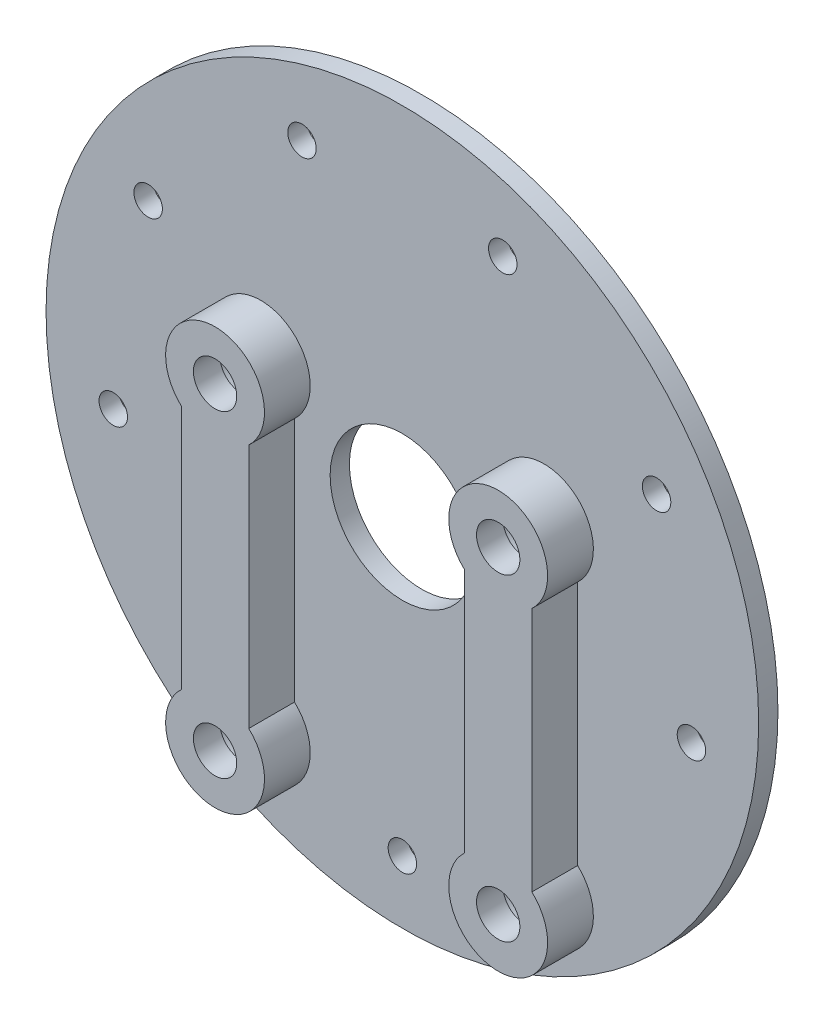
from build123d import *

# Parameters (mm, degrees)
IZIM1_W                          = 37
IZIM1_H                          = 2
Y_KSEKLIK_EKSTR_ZYON1_DEPTH      = 4.75
Y_KSEKLIK_EKSTR_ZYON2_DEPTH      = 4.75
DELIK1_D                         = 2.95656
DELIK1_DEPTH                     = 2
F_0_15_0_15_DIAMETER_HOLE1_D     = 15
F_0_15_0_15_DIAMETER_HOLE1_DEPTH = 6.75
M7X1_0_TAPPED_HOLE1_D            = 4.5
M7X1_0_TAPPED_HOLE1_DEPTH        = 6.75
M7X1_0_TAPPED_HOLE1_CBORE_D      = 7
M7X1_0_TAPPED_HOLE1_CBORE_DEPTH  = 4


with BuildPart() as part:
    # Çizim1 → Döndür1 (revolve)
    with BuildSketch(Plane(origin=(0, 0, 0), x_dir=(1, 0, 0), z_dir=(0, 1, 0))):
        with Locations((18.5, -1)):
            Rectangle(IZIM1_W, IZIM1_H)
    revolve(axis=Axis((0, 0, 0), (0, 0, 1)))

    # Çizim2 → Yükseklik-Ekstrüzyon1 (add)
    with BuildSketch(Plane.XY.offset(2)):
        with BuildLine():
            Line((-18.2, -22.246481648), (-18.2, 3.246418008))
            ThreePointArc((-18.2, 3.246418008), (-14.7, 12.132116892), (-11.2, 3.246418008))
            Line((-11.2, 3.246418008), (-11.2, -22.246481648))
            ThreePointArc((-11.2, -22.246481648), (-14.7, -31.132180531), (-18.2, -22.246481648))
        make_face()
    extrude(amount=Y_KSEKLIK_EKSTR_ZYON1_DEPTH)

    # Çizim3 → Yükseklik-Ekstrüzyon2 (add)
    with BuildSketch(Plane.XY.offset(2)):
        with BuildLine():
            Line((18.2, 3.246418008), (18.2, -22.246481648))
            ThreePointArc((18.2, -22.246481648), (14.7, -31.132180531), (11.2, -22.246481648))
            Line((11.2, -22.246481648), (11.2, 3.246418008))
            ThreePointArc((11.2, 3.246418008), (14.7, 12.132116892), (18.2, 3.246418008))
        make_face()
    extrude(amount=Y_KSEKLIK_EKSTR_ZYON2_DEPTH)

    # Delik1
    with Locations(Plane.XY.offset(2)):
        with Locations((-30.016940312, -5.292796455), (-26.396454307, 15.24), (-10.424773969, 28.641831082), (10.424773969, 28.641831082), (26.396454307, 15.24), (30.016940312, -5.292796455), (0, -30.48)):
            Hole(DELIK1_D / 2, depth=DELIK1_DEPTH)

    # Ø0.15 (0.15) Diameter Hole1
    with Locations(Plane(origin=(0, 0, 0), x_dir=(-1, 0, 0), z_dir=(0, 0, -1))):
        with Locations((0, 0)):
            Hole(F_0_15_0_15_DIAMETER_HOLE1_D / 2, depth=F_0_15_0_15_DIAMETER_HOLE1_DEPTH)

    # M7x1.0 Tapped Hole1
    with Locations(Plane(origin=(0, 0, 0), x_dir=(-1, 0, 0), z_dir=(0, 0, -1))):
        with Locations((14.7, -26), (-14.7, 6.999957574), (-14.7, -26), (14.7, 6.999957574)):
            CounterBoreHole(M7X1_0_TAPPED_HOLE1_D / 2, M7X1_0_TAPPED_HOLE1_CBORE_D / 2, M7X1_0_TAPPED_HOLE1_CBORE_DEPTH, depth=M7X1_0_TAPPED_HOLE1_DEPTH)


solid = part.part
